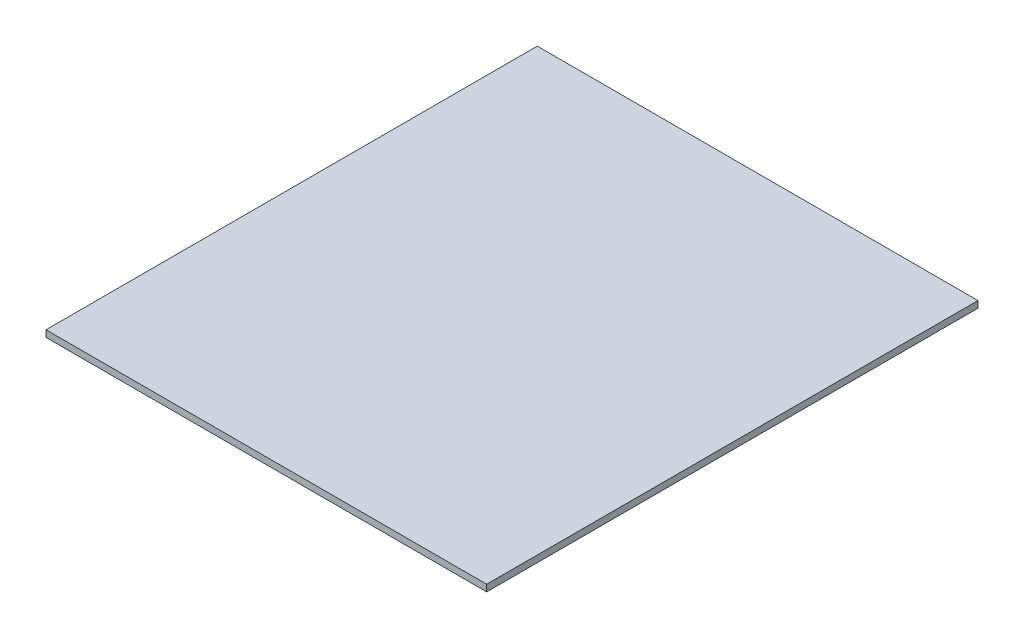
from build123d import *

# Parameters (mm, degrees)
SKETCH1_W           = 662
SKETCH1_H           = 738
BOSS_EXTRUDE1_DEPTH = 10


with BuildPart() as part:
    # Sketch1 → Boss-Extrude1 (new body)
    with BuildSketch(Plane(origin=(0, 0, 0), x_dir=(1, 0, 0), z_dir=(0, 1, 0))):
        Rectangle(SKETCH1_W, SKETCH1_H)
    extrude(amount=-BOSS_EXTRUDE1_DEPTH)


solid = part.part
